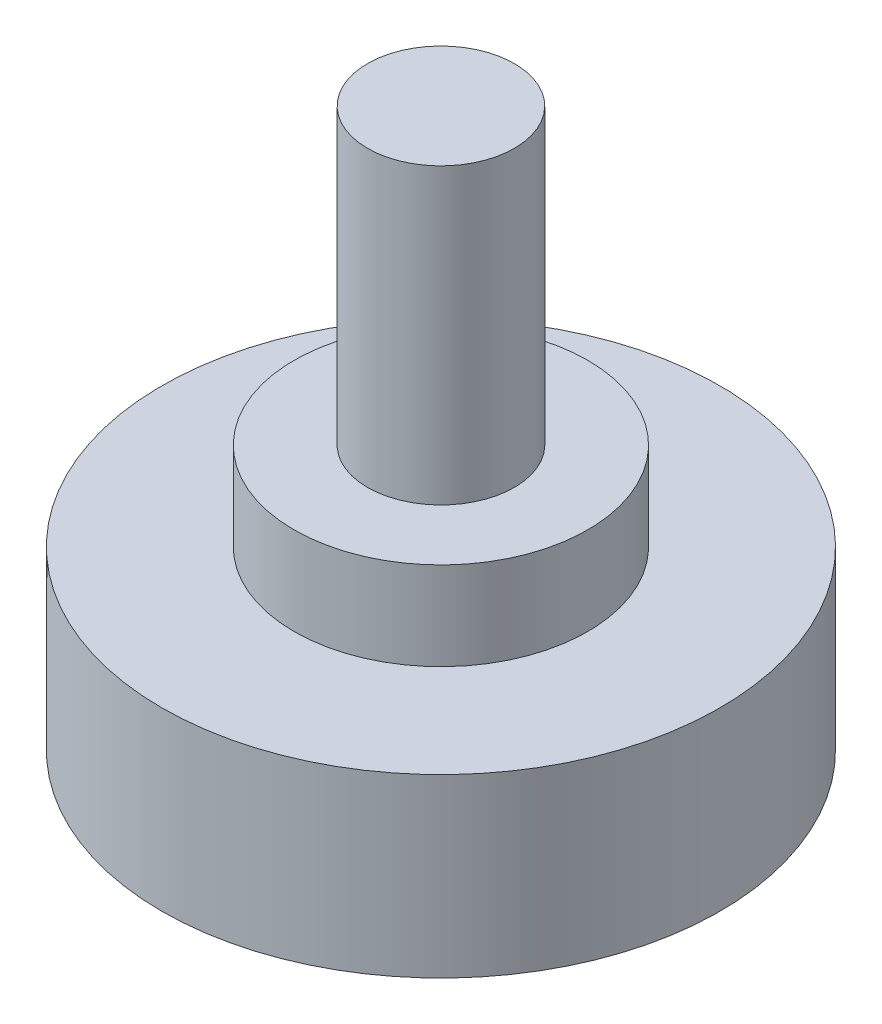
from build123d import *

# Parameters (mm, degrees)
SKETCH_1_R      = 19
EXTRUDE_1_DEPTH = 12
SKETCH_2_R      = 10
EXTRUDE_2_DEPTH = 6
SKETCH_3_R      = 5
EXTRUDE_3_DEPTH = 20


with BuildPart() as part:
    # 草图1 → 凸台-拉伸1 (new body)
    with BuildSketch(Plane(origin=(0, 0, 0), x_dir=(1, 0, 0), z_dir=(0, 1, 0))):
        Circle(SKETCH_1_R)
    extrude(amount=EXTRUDE_1_DEPTH)

    # 草图2 → 凸台-拉伸2 (add)
    with BuildSketch(Plane(origin=(0, 12, 0), x_dir=(1, 0, 0), z_dir=(0, 1, 0))):
        Circle(SKETCH_2_R)
    extrude(amount=EXTRUDE_2_DEPTH)

    # 草图3 → 凸台-拉伸3 (add)
    with BuildSketch(Plane(origin=(0, 18, 0), x_dir=(1, 0, 0), z_dir=(0, 1, 0))):
        Circle(SKETCH_3_R)
    extrude(amount=EXTRUDE_3_DEPTH)


solid = part.part
